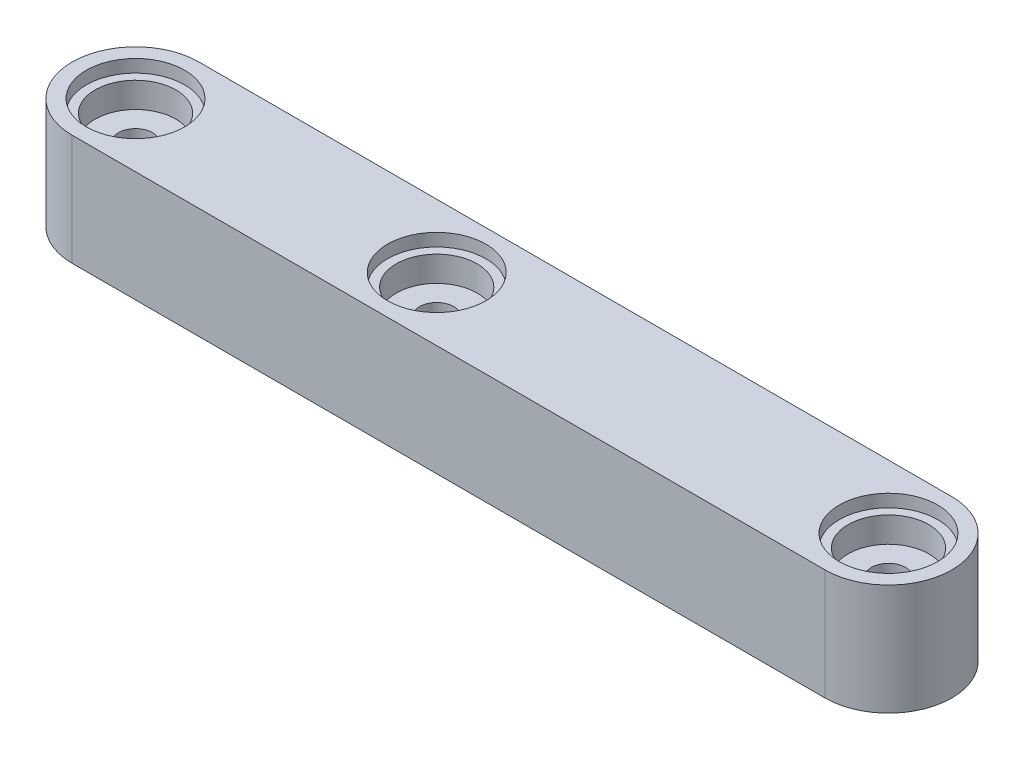
from build123d import *

# Parameters (mm, degrees)
SKETCH_1_R          = 1.075
EXTRUDE_1_DEPTH     = 7
SKETCH_3_R          = 2.55
CUT_EXTRUDE_1_DEPTH = 2.4
SKETCH_4_R          = 3.1
CUT_EXTRUDE_3_DEPTH = 0.8


with BuildPart() as part:
    # 草图1 → 凸台-拉伸1 (new body)
    with BuildSketch(Plane(origin=(0, 0, 0), x_dir=(1, 0, 0), z_dir=(0, 1, 0))):
        with BuildLine():
            Line((0, 0), (47.5, 0))
            ThreePointArc((47.5, 0), (51.5, -4), (47.5, -8))
            Line((47.5, -8), (0, -8))
            ThreePointArc((0, -8), (-4, -4), (0, 0))
        make_face()
        with Locations((0, -4)):
            Circle(SKETCH_1_R, mode=Mode.SUBTRACT)
        with Locations((19, -4)):
            Circle(SKETCH_1_R, mode=Mode.SUBTRACT)
        with Locations((47.5, -4)):
            Circle(SKETCH_1_R, mode=Mode.SUBTRACT)
    extrude(amount=EXTRUDE_1_DEPTH)

    # 草图3 → 切除-拉伸1 (cut)
    with BuildSketch(Plane(origin=(0, 7, 0), x_dir=(1, 0, 0), z_dir=(0, 1, 0))):
        with Locations((0, -4)):
            Circle(SKETCH_3_R)
        with Locations((19, -4)):
            Circle(SKETCH_3_R)
        with Locations((47.5, -4)):
            Circle(SKETCH_3_R)
    extrude(amount=-CUT_EXTRUDE_1_DEPTH, mode=Mode.SUBTRACT)

    # 草图4 → 切除-拉伸3 (cut)
    with BuildSketch(Plane(origin=(0, 7, 0), x_dir=(1, 0, 0), z_dir=(0, 1, 0))):
        with Locations((0, -4)):
            Circle(SKETCH_4_R)
        with Locations((19, -4)):
            Circle(SKETCH_4_R)
        with Locations((47.5, -4)):
            Circle(SKETCH_4_R)
    extrude(amount=-CUT_EXTRUDE_3_DEPTH, mode=Mode.SUBTRACT)


solid = part.part
